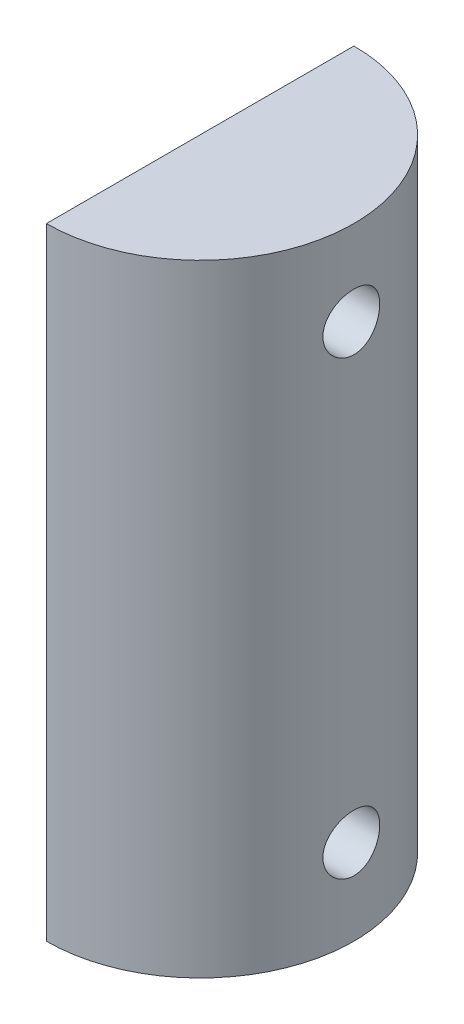
from build123d import *

# Parameters (mm, degrees)
BOSS_EXTRUDE2_DEPTH = 131.3737
SKETCH2_R           = 6
CUT_EXTRUDE1_DEPTH  = 59


with BuildPart() as part:
    # Sketch1 → Boss-Extrude2 (new body)
    with BuildSketch(Plane(origin=(0, 0, 0), x_dir=(1, 0, 0), z_dir=(0, 1, 0))):
        with BuildLine():
            ThreePointArc((32.5, 0), (22.980970389, 22.980970389), (0, 32.5))
            Line((0, 32.5), (0, -32.5))
            ThreePointArc((0, -32.5), (22.980970389, -22.980970389), (32.5, 0))
        make_face()
    extrude(amount=-BOSS_EXTRUDE2_DEPTH)

    # Sketch2 → Cut-Extrude1 (cut)
    with BuildSketch(Plane.ZY):
        with Locations((0, -18)):
            Circle(SKETCH2_R)
        with Locations((0, -113.3737)):
            Circle(SKETCH2_R)
    extrude(amount=-CUT_EXTRUDE1_DEPTH, mode=Mode.SUBTRACT)


solid = part.part
